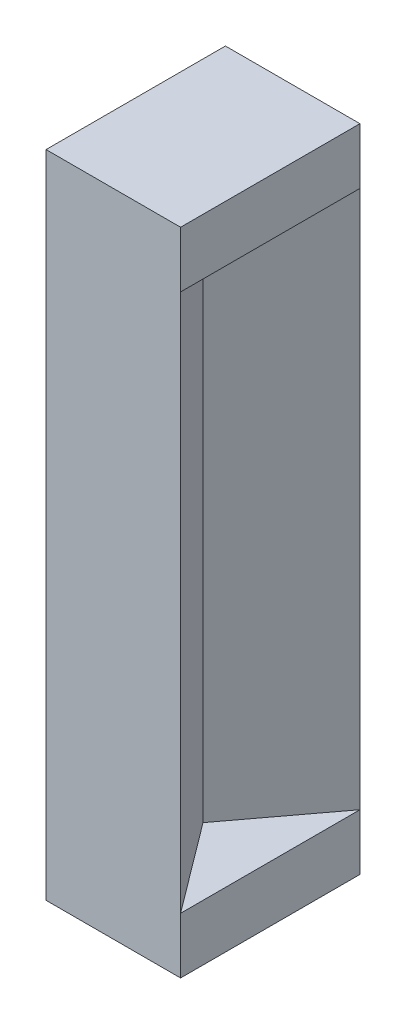
from build123d import *

# Parameters (mm, degrees)
SKETCH3_W           = 60
SKETCH3_H           = 80
BOSS_EXTRUDE1_DEPTH = 25
SKETCH4_W           = 60
SKETCH4_H           = 80
BOSS_EXTRUDE2_DEPTH = 25
BOSS_EXTRUDE3_DEPTH = 240
BOSS_EXTRUDE4_DEPTH = 240


with BuildPart() as part:
    # Sketch3 → Boss-Extrude1 (new body)
    with BuildSketch(Plane(origin=(0, -266.5409196, 0), x_dir=(-1, 0, 0), z_dir=(0, -1, 0))):
        with Locations((-150, 40)):
            Rectangle(SKETCH3_W, SKETCH3_H)
    extrude(amount=BOSS_EXTRUDE1_DEPTH)



with BuildPart() as body_2:
    # Sketch4 → Boss-Extrude2 (new body)
    with BuildSketch(Plane(origin=(0, -26.5409196, 0), x_dir=(1, 0, 0), z_dir=(0, 1, 0))):
        with Locations((150, 40)):
            Rectangle(SKETCH4_W, SKETCH4_H)
    extrude(amount=BOSS_EXTRUDE2_DEPTH)


with BuildPart() as part_1:
    add(part.part)

    add(body_2.part)  # Boss-Extrude3 merges body 2
    # Sketch5 → Boss-Extrude3 (add)
    with BuildSketch(Plane(origin=(0, -266.5409196, 0), x_dir=(1, 0, 0), z_dir=(0, 1, 0))):
        Polygon((120, 80), (180, 0), (120, 0), align=None)
    extrude(amount=BOSS_EXTRUDE3_DEPTH)

    # Sketch6 → Boss-Extrude4 (add)
    with BuildSketch(Plane(origin=(0, -266.5409196, 0), x_dir=(1, 0, 0), z_dir=(0, 1, 0))):
        Polygon((120, 80), (180, 80), (120, 0), align=None)
    extrude(amount=BOSS_EXTRUDE4_DEPTH)


solid = part_1.part
